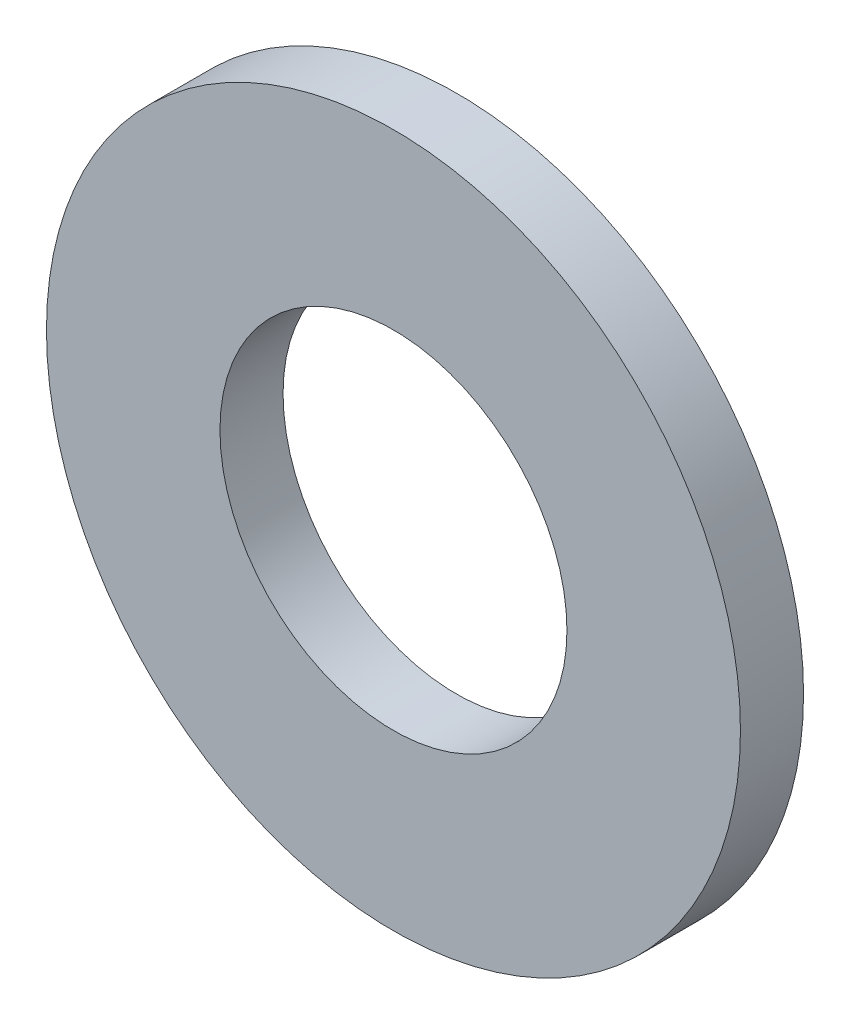
from build123d import *

# Parameters (mm, degrees)
SKETCH_1_R      = 5.5
SKETCH_1_R_2    = 2.75
EXTRUDE_1_DEPTH = 1


with BuildPart() as part:
    # Эскиз1 → Бобышка-Вытянуть1 (new body)
    with BuildSketch(Plane.XY):
        Circle(SKETCH_1_R)
        Circle(SKETCH_1_R_2, mode=Mode.SUBTRACT)
    extrude(amount=EXTRUDE_1_DEPTH)


solid = part.part
